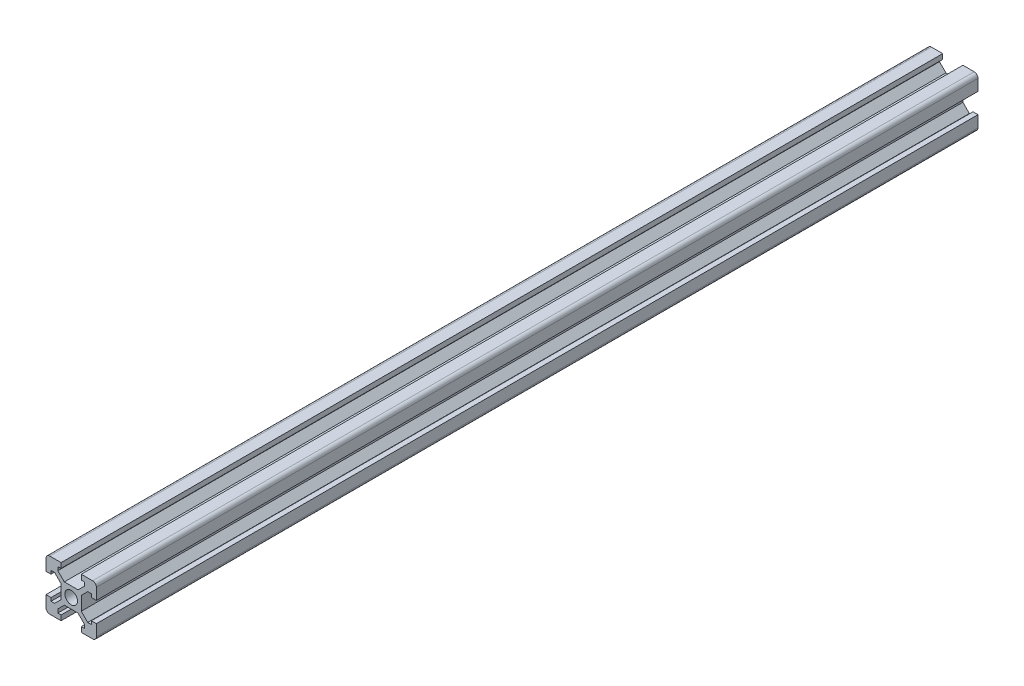
from build123d import *

# Parameters (mm, degrees)
SKETCH_1_R      = 2.5
EXTRUDE_1_DEPTH = 350
FILLET_1_R      = 1.5


with BuildPart() as part:
    # Эскиз1 → Бобышка-Вытянуть1 (new body)
    with BuildSketch(Plane.XY):
        Polygon((14, 20), (20, 20), (20, 14), (18, 14), (18, 15.3), (16.572792206, 15.3), (14, 12.727207794), (14, 7.272792206), (16.572792206, 4.7), (18, 4.7), (18, 6), (20, 6), (20, 0), (14, 0), (14, 2), (15.3, 2), (15.3, 3.427207794), (12.684044775, 6), (7.272792206, 6), (4.7, 3.427207794), (4.7, 2), (6, 2), (6, 0), (0, 0), (0, 6), (2, 6), (2, 4.7), (3.427207794, 4.7), (6, 7.272792206), (6, 12.727207794), (3.427207794, 15.3), (2, 15.3), (2, 14), (0, 14), (0, 20), (6, 20), (6, 18), (4.7, 18), (4.7, 16.572792206), (7.272792206, 14), (12.727207794, 14), (15.3, 16.572792206), (15.3, 18), (14, 18), align=None)
        with Locations((10, 10)):
            Circle(SKETCH_1_R, mode=Mode.SUBTRACT)
    extrude(amount=EXTRUDE_1_DEPTH)

    # Скругление1
    fillet_1_edges = [part.edges().sort_by_distance(p)[0] for p in [
        (0, 20, 175),
        (20, 20, 175),
        (20, 0, 175),
        (0, 0, 175),
    ]]
    fillet(fillet_1_edges, radius=FILLET_1_R)


solid = part.part
